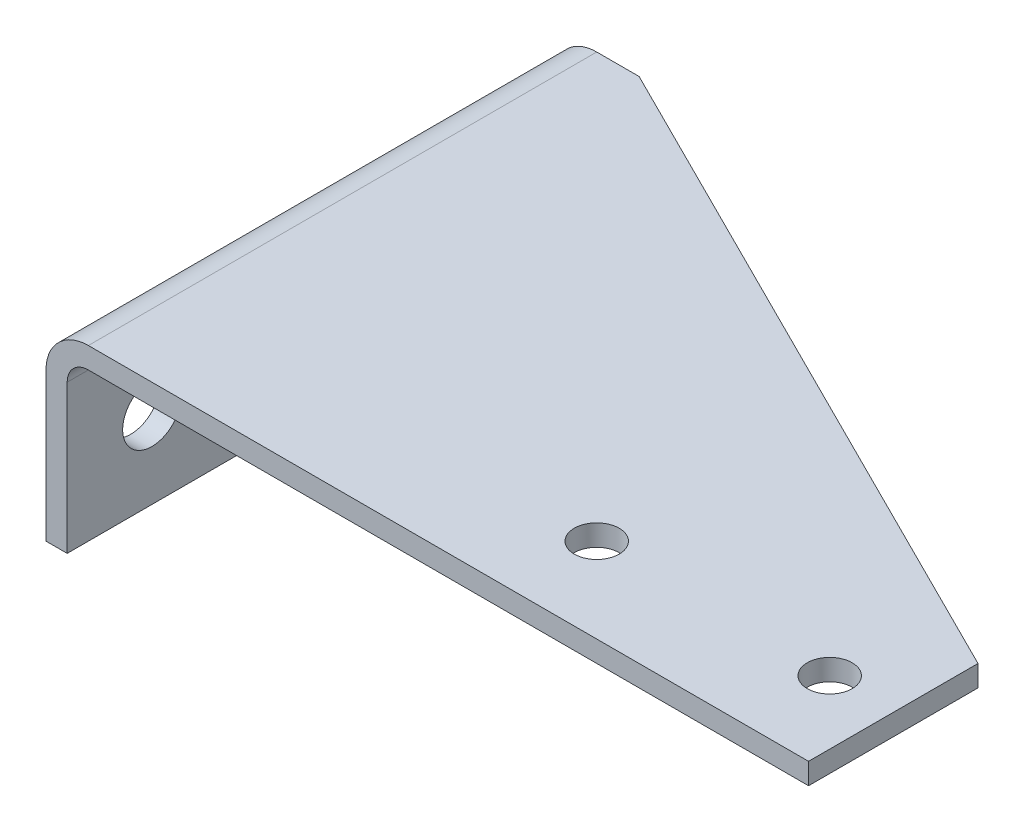
from build123d import *

# Parameters (mm, degrees)
EXTRUDE1_DEPTH         = 127
SKETCH2_R              = 6.731
CUT_CHAMFER_DEPTH      = 508
CUT_CHAMFER_DEPTH_BACK = 58.15
SKETCH3_R              = 8.763
CUT_HOLES_DEPTH        = 229.6
CUT_LH_DEPTH           = 1
CUT_LH_DEPTH_BACK      = 58.15


with BuildPart() as part:
    # Sketch1 → Extrude1 (new body, symmetric)
    with BuildSketch(Plane.XY):
        with BuildLine():
            Line((228.6, 0), (12.7, 0))
            ThreePointArc((12.7, 0), (3.719743879, -3.719743879), (0, -12.7))
            Line((0, -12.7), (0, -57.15))
            Line((0, -57.15), (6.35, -57.15))
            Line((6.35, -57.15), (6.35, -12.7))
            ThreePointArc((6.35, -12.7), (8.209871939, -8.209871939), (12.7, -6.35))
            Line((12.7, -6.35), (228.6, -6.35))
            Line((228.6, -6.35), (228.6, 0))
        make_face()
    extrude(amount=EXTRUDE1_DEPTH, both=True)

    # Sketch2 → Cut-Chamfer (cut, two sides)
    with BuildSketch(Plane(origin=(0, 0, 0), x_dir=(1, 0, 0), z_dir=(0, 1, 0))) as cut_chamfer_sk:
        with Locations((209.55, 0)):
            Circle(SKETCH2_R)
        with Locations((139.7, 0)):
            Circle(SKETCH2_R)
        Polygon((25.4, 127), (228.6, 25.4), (228.6, 127), align=None)
        Polygon((25.4, -127), (228.6, -25.4), (228.6, -127), align=None)
    extrude(amount=CUT_CHAMFER_DEPTH, mode=Mode.SUBTRACT)
    extrude(cut_chamfer_sk.sketch, amount=-CUT_CHAMFER_DEPTH_BACK, mode=Mode.SUBTRACT)

    # Sketch3 → Cut-Holes (cut, through all)
    with BuildSketch(Plane(origin=(0, 0, 0), x_dir=(0, 0, -1), z_dir=(1, 0, 0))):
        with Locations((0, -33.3375)):
            Circle(SKETCH3_R)
        with Locations((101.6, -33.3375)):
            Circle(SKETCH3_R)
        with Locations((0, -153.9875)):
            Circle(SKETCH3_R)
        with Locations((101.6, -153.9875)):
            Circle(SKETCH3_R)
        with Locations((-101.6, -33.3375)):
            Circle(SKETCH3_R)
        with Locations((-101.6, -153.9875)):
            Circle(SKETCH3_R)
    extrude(amount=CUT_HOLES_DEPTH, mode=Mode.SUBTRACT)

    # Sketch5 → Cut-LH (cut, two sides)
    with BuildSketch(Plane(origin=(0, 0, 0), x_dir=(1, 0, 0), z_dir=(0, 1, 0))) as cut_lh_sk:
        Polygon((788.086014381, -25.4), (228.6, -25.4), (0, -25.4), (-559.486014381, -25.4), (-559.486014381, -1144.372028761), (788.086014381, -1144.372028761), align=None)
    extrude(amount=CUT_LH_DEPTH, mode=Mode.SUBTRACT)
    extrude(cut_lh_sk.sketch, amount=-CUT_LH_DEPTH_BACK, mode=Mode.SUBTRACT)


solid = part.part
